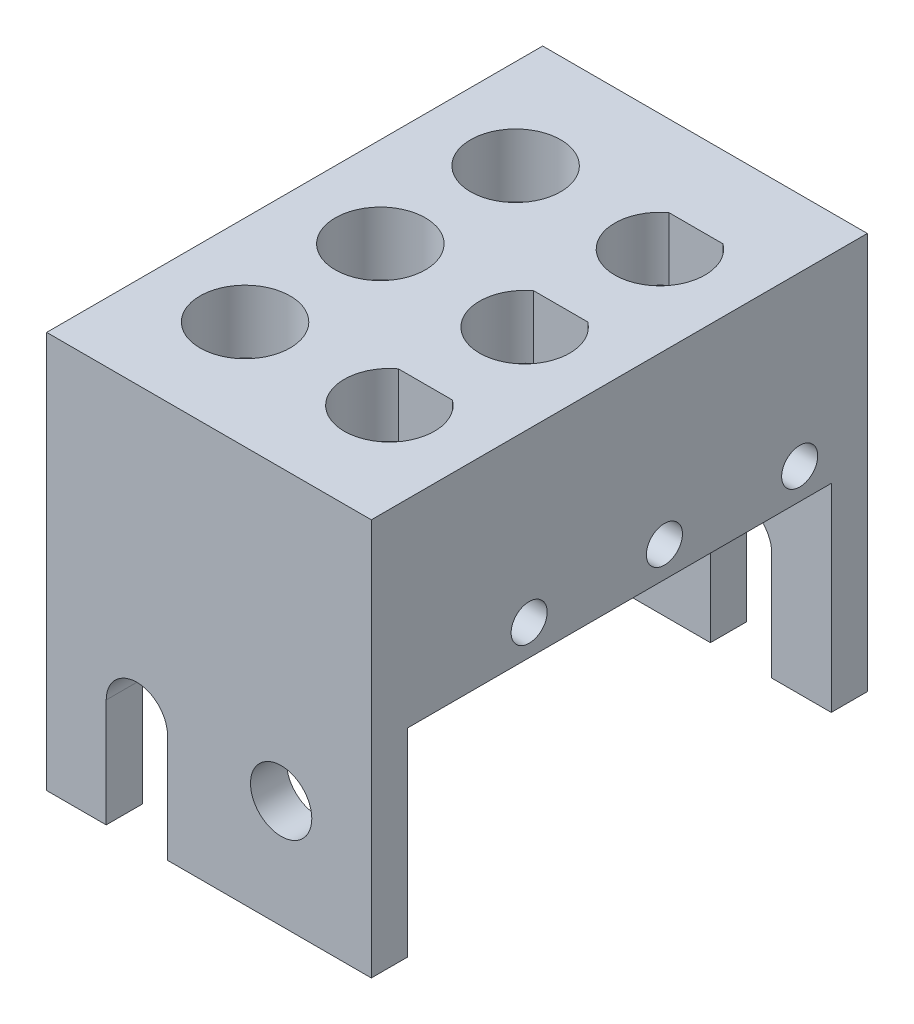
from build123d import *

# Parameters (mm, degrees)
SKETCH_1_W               = 18
SKETCH_1_H               = 27.5
SKETCH_1_R               = 2.5
TOP_SURFACE_DEPTH        = 3.5
SKETCH_2_R               = 1.7
FRONT_WALL_DEPTH         = 2
PATTERN_CIRCULAR_1_COUNT = 2
SIDE_RAILS_DEPTH         = 27.5
SKETCH_4_R               = 1
SEPARATORS_CUTOUTS_DEPTH = 9
PATTERN_CIRCULAR_5_COUNT = 2


with BuildPart() as part:
    # Эскиз1 → top-surface (new body)
    with BuildSketch(Plane(origin=(0, 0, 0), x_dir=(1, 0, 0), z_dir=(0, 1, 0))):
        Rectangle(SKETCH_1_W, SKETCH_1_H)
        with Locations(Location((-4, 7.25, 0), (0, 0, 270))):
            Circle(SKETCH_1_R, mode=Mode.SUBTRACT)
        with Locations(Location((-4, -0.25, 0), (0, 0, 270))):
            Circle(SKETCH_1_R, mode=Mode.SUBTRACT)
        with Locations(Location((-4, -7.75, 0), (0, 0, 270))):
            Circle(SKETCH_1_R, mode=Mode.SUBTRACT)
        with BuildLine():
            Line((2.5, 9.25), (5.5, 9.25))
            ThreePointArc((5.5, 9.25), (4, 4.75), (2.5, 9.25))
        make_face(mode=Mode.SUBTRACT)
        with BuildLine():
            Line((2.5, 1.75), (5.5, 1.75))
            ThreePointArc((5.5, 1.75), (4, -2.75), (2.5, 1.75))
        make_face(mode=Mode.SUBTRACT)
        with BuildLine():
            Line((2.5, -5.75), (5.5, -5.75))
            ThreePointArc((5.5, -5.75), (4, -10.25), (2.5, -5.75))
        make_face(mode=Mode.SUBTRACT)
    extrude(amount=-TOP_SURFACE_DEPTH)

    # Эскиз2 → front-wall (add)
    with BuildSketch(Plane.XY.offset(13.75)):
        with BuildLine():
            Line((9, -3.5), (-9, -3.5))
            Line((-9, -3.5), (-9, -22))
            Line((-9, -22), (-5.7, -22))
            Line((-5.7, -22), (-5.7, -16))
            ThreePointArc((-5.7, -16), (-4, -14.3), (-2.3, -16))
            Line((-2.3, -16), (-2.3, -22))
            Line((-2.3, -22), (9, -22))
            Line((9, -22), (9, -3.5))
        make_face()
        with Locations((4, -16)):
            Circle(SKETCH_2_R, mode=Mode.SUBTRACT)
    front_wall = extrude(amount=-FRONT_WALL_DEPTH)

    # Круговой массив1: front-wall ×2 about axis
    pattern_circular_1_axis = Axis((0, 0, 0), (0, 1, 0))
    for i in range(1, PATTERN_CIRCULAR_1_COUNT):
        add(front_wall.rotate(pattern_circular_1_axis, i * 360 / PATTERN_CIRCULAR_1_COUNT))

    # Эскиз5 → side-rails (add)
    with BuildSketch(Plane.XY.offset(13.75)):
        Polygon((-9, -1.5), (-9, -11), (-7, -11), (-6.3, -10.3), (-6.3, -8.3), (-7, -7.6), (-7, -1.5), align=None)
        Polygon((-1.7, -8.3), (-1, -7.6), (-1, -1.5), (0, -1.5), (0, -11), (-1, -11), (-1.7, -10.3), align=None)
    side_rails = extrude(amount=-SIDE_RAILS_DEPTH)

    # Эскиз4 → separators-cutouts (cut)
    with BuildSketch(Plane.ZY.offset(9)):
        with Locations((-5, -9.3)):
            Circle(SKETCH_4_R)
        with Locations((2.5, -9.3)):
            Circle(SKETCH_4_R)
        with Locations((10, -9.3)):
            Circle(SKETCH_4_R)
    separators_cutouts = extrude(amount=-SEPARATORS_CUTOUTS_DEPTH, mode=Mode.SUBTRACT)

    # Круговой массив5: side-rails, separators-cutouts ×2 about axis
    pattern_circular_5_axis = Axis((0, 0, 0), (0, 1, 0))
    add([side_rails.rotate(pattern_circular_5_axis, i * 360 / PATTERN_CIRCULAR_5_COUNT) for i in range(1, PATTERN_CIRCULAR_5_COUNT)])
    add([separators_cutouts.rotate(pattern_circular_5_axis, i * 360 / PATTERN_CIRCULAR_5_COUNT) for i in range(1, PATTERN_CIRCULAR_5_COUNT)], mode=Mode.SUBTRACT)


solid = part.part
